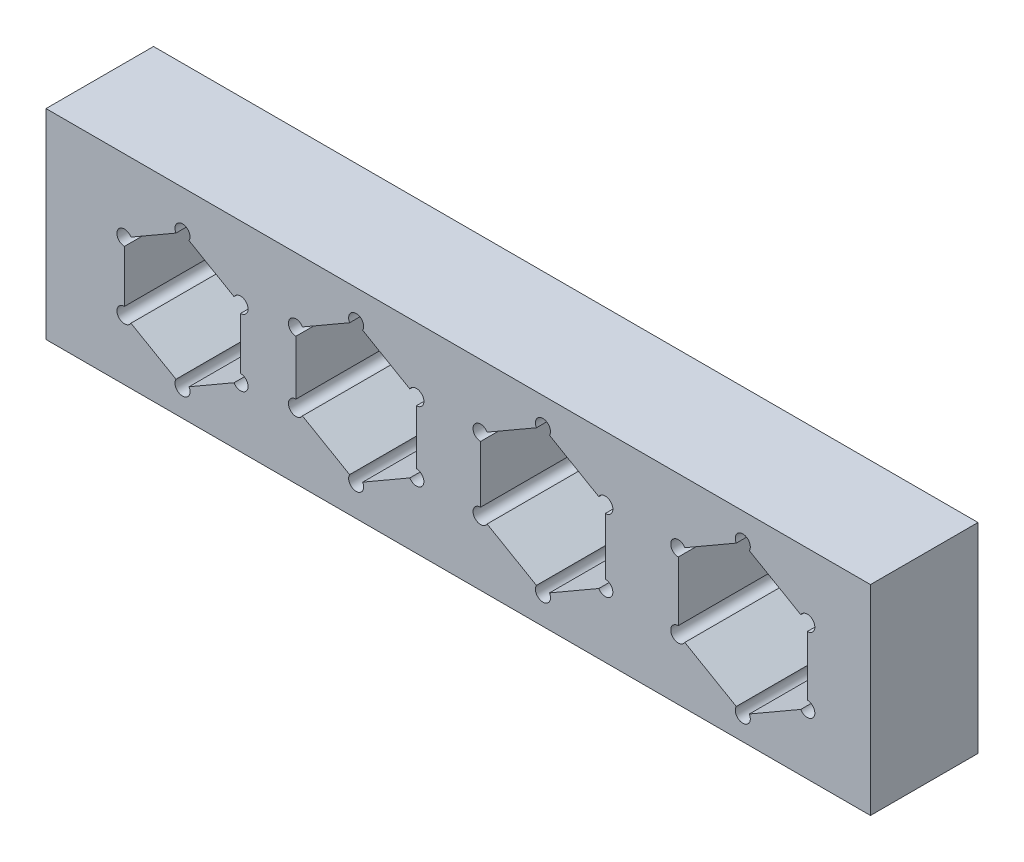
from build123d import *

# Parameters (mm, degrees)
SKETCH1_W           = 38.338603818
SKETCH1_H           = 9.300852407
BOSS_EXTRUDE1_DEPTH = 5


with BuildPart() as part:
    # Sketch1 → Boss-Extrude1 (new body)
    with BuildSketch(Plane.XY):
        with Locations((4.747182706, -0.026965663)):
            Rectangle(SKETCH1_W, SKETCH1_H)
        with BuildLine():
            Line((-8.377929756, 2.630922308), (-10.471711974, 1.422076581))
            ThreePointArc((-10.471711974, 1.422076581), (-11.077929756, 1.422076581), (-10.774820865, 0.897076581))
            Line((-10.774820865, 0.897076581), (-10.774820865, -1.520614872))
            ThreePointArc((-10.774820865, -1.520614872), (-11.077929756, -2.045614872), (-10.471711974, -2.045614872))
            Line((-10.471711974, -2.045614872), (-8.377929756, -3.254460599))
            ThreePointArc((-8.377929756, -3.254460599), (-8.074820865, -3.779460599), (-7.771711974, -3.254460599))
            Line((-7.771711974, -3.254460599), (-5.677929756, -2.045614872))
            ThreePointArc((-5.677929756, -2.045614872), (-5.071711974, -2.045614872), (-5.374820865, -1.520614872))
            Line((-5.374820865, -1.520614872), (-5.374820865, 0.897076581))
            ThreePointArc((-5.374820865, 0.897076581), (-5.071711974, 1.422076581), (-5.677929756, 1.422076581))
            Line((-5.677929756, 1.422076581), (-7.771711974, 2.630922308))
            ThreePointArc((-7.771711974, 2.630922308), (-8.074820865, 3.155922308), (-8.377929756, 2.630922308))
        make_face(mode=Mode.SUBTRACT)
        with BuildLine():
            Line((-0.303108891, 3.058161507), (-2.496891109, 1.791580754))
            ThreePointArc((-2.496891109, 1.791580754), (-3.103108891, 1.791580754), (-2.8, 1.266580754))
            Line((-2.8, 1.266580754), (-2.8, -1.266580754))
            ThreePointArc((-2.8, -1.266580754), (-3.103108891, -1.791580754), (-2.496891109, -1.791580754))
            Line((-2.496891109, -1.791580754), (-0.303108891, -3.058161507))
            ThreePointArc((-0.303108891, -3.058161507), (0, -3.583161507), (0.303108891, -3.058161507))
            Line((0.303108891, -3.058161507), (2.496891109, -1.791580754))
            ThreePointArc((2.496891109, -1.791580754), (3.103108891, -1.791580754), (2.8, -1.266580754))
            Line((2.8, -1.266580754), (2.8, 1.266580754))
            ThreePointArc((2.8, 1.266580754), (3.103108891, 1.791580754), (2.496891109, 1.791580754))
            Line((2.496891109, 1.791580754), (0.303108891, 3.058161507))
            ThreePointArc((0.303108891, 3.058161507), (0, 3.583161507), (-0.303108891, 3.058161507))
        make_face(mode=Mode.SUBTRACT)
        with BuildLine():
            Line((8.383417443, 3.171942265), (6.089635226, 1.847626484))
            ThreePointArc((6.089635226, 1.847626484), (5.483417443, 1.847626484), (5.786526334, 1.322626484))
            Line((5.786526334, 1.322626484), (5.786526334, -1.326005077))
            ThreePointArc((5.786526334, -1.326005077), (5.483417443, -1.851005077), (6.089635226, -1.851005077))
            Line((6.089635226, -1.851005077), (8.383417443, -3.175320858))
            ThreePointArc((8.383417443, -3.175320858), (8.686526334, -3.700320858), (8.989635226, -3.175320858))
            Line((8.989635226, -3.175320858), (11.283417443, -1.851005077))
            ThreePointArc((11.283417443, -1.851005077), (11.889635226, -1.851005077), (11.586526334, -1.326005077))
            Line((11.586526334, -1.326005077), (11.586526334, 1.322626484))
            ThreePointArc((11.586526334, 1.322626484), (11.889635226, 1.847626484), (11.283417443, 1.847626484))
            Line((11.283417443, 1.847626484), (8.989635226, 3.171942265))
            ThreePointArc((8.989635226, 3.171942265), (8.686526334, 3.696942265), (8.383417443, 3.171942265))
        make_face(mode=Mode.SUBTRACT)
        with BuildLine():
            Line((17.676043737, 3.17263624), (15.28226152, 1.790585433))
            ThreePointArc((15.28226152, 1.790585433), (14.676043737, 1.790585433), (14.979152629, 1.265585433))
            Line((14.979152629, 1.265585433), (14.979152629, -1.498516182))
            ThreePointArc((14.979152629, -1.498516182), (14.676043737, -2.023516182), (15.28226152, -2.023516182))
            Line((15.28226152, -2.023516182), (17.676043737, -3.40556699))
            ThreePointArc((17.676043737, -3.40556699), (17.979152629, -3.93056699), (18.28226152, -3.40556699))
            Line((18.28226152, -3.40556699), (20.676043737, -2.023516182))
            ThreePointArc((20.676043737, -2.023516182), (21.28226152, -2.023516182), (20.979152629, -1.498516182))
            Line((20.979152629, -1.498516182), (20.979152629, 1.265585433))
            ThreePointArc((20.979152629, 1.265585433), (21.28226152, 1.790585433), (20.676043737, 1.790585433))
            Line((20.676043737, 1.790585433), (18.28226152, 3.17263624))
            ThreePointArc((18.28226152, 3.17263624), (17.979152629, 3.69763624), (17.676043737, 3.17263624))
        make_face(mode=Mode.SUBTRACT)
    extrude(amount=BOSS_EXTRUDE1_DEPTH)


solid = part.part
